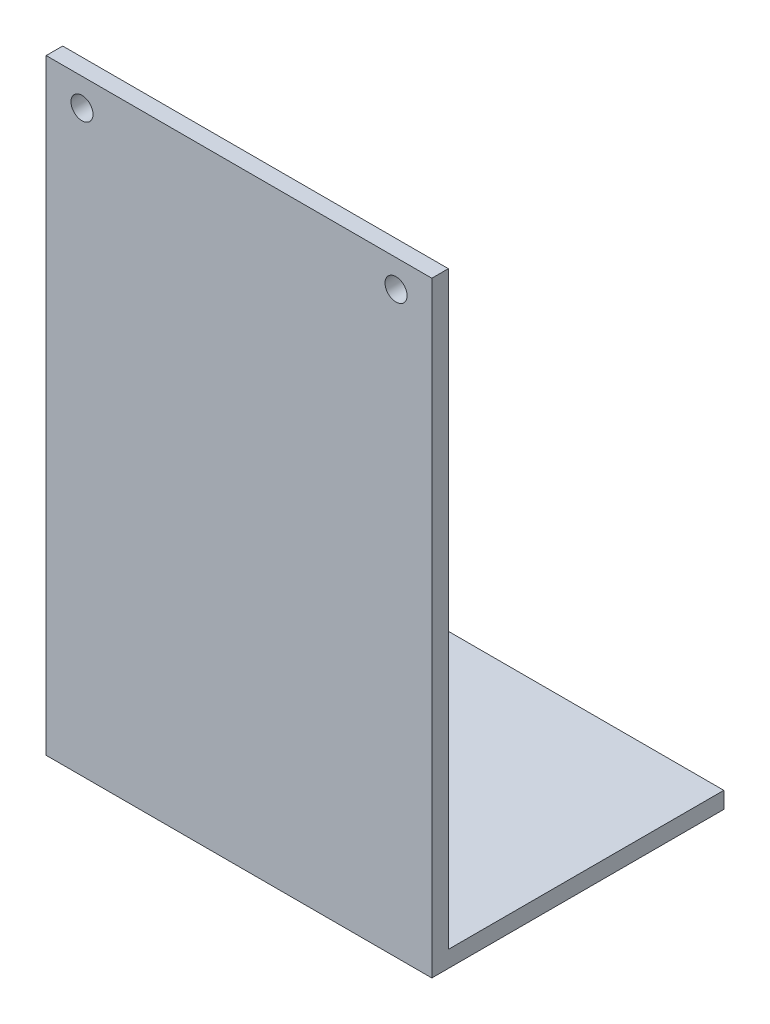
from build123d import *

# Parameters (mm, degrees)
SKETCH1_W           = 70
SKETCH1_H           = 110
BOSS_EXTRUDE1_DEPTH = 3
SKETCH2_W           = 70
SKETCH2_H           = 3
BOSS_EXTRUDE2_DEPTH = 50
SKETCH3_R           = 2
CUT_EXTRUDE1_DEPTH  = 3


with BuildPart() as part:
    # Sketch1 → Boss-Extrude1 (new body)
    with BuildSketch(Plane.XY):
        Rectangle(SKETCH1_W, SKETCH1_H)
    extrude(amount=BOSS_EXTRUDE1_DEPTH)

    # Sketch2 → Boss-Extrude2 (add)
    with BuildSketch(Plane(origin=(0, 0, 0), x_dir=(-1, 0, 0), z_dir=(0, 0, -1))):
        with Locations((0, -53.5)):
            Rectangle(SKETCH2_W, SKETCH2_H)
    extrude(amount=BOSS_EXTRUDE2_DEPTH)

    # Sketch3 → Cut-Extrude1 (cut)
    with BuildSketch(Plane.XY.offset(3)):
        with Locations((-28.5, 50)):
            Circle(SKETCH3_R)
        with Locations((28.5, 50)):
            Circle(SKETCH3_R)
    extrude(amount=-CUT_EXTRUDE1_DEPTH, mode=Mode.SUBTRACT)


solid = part.part
